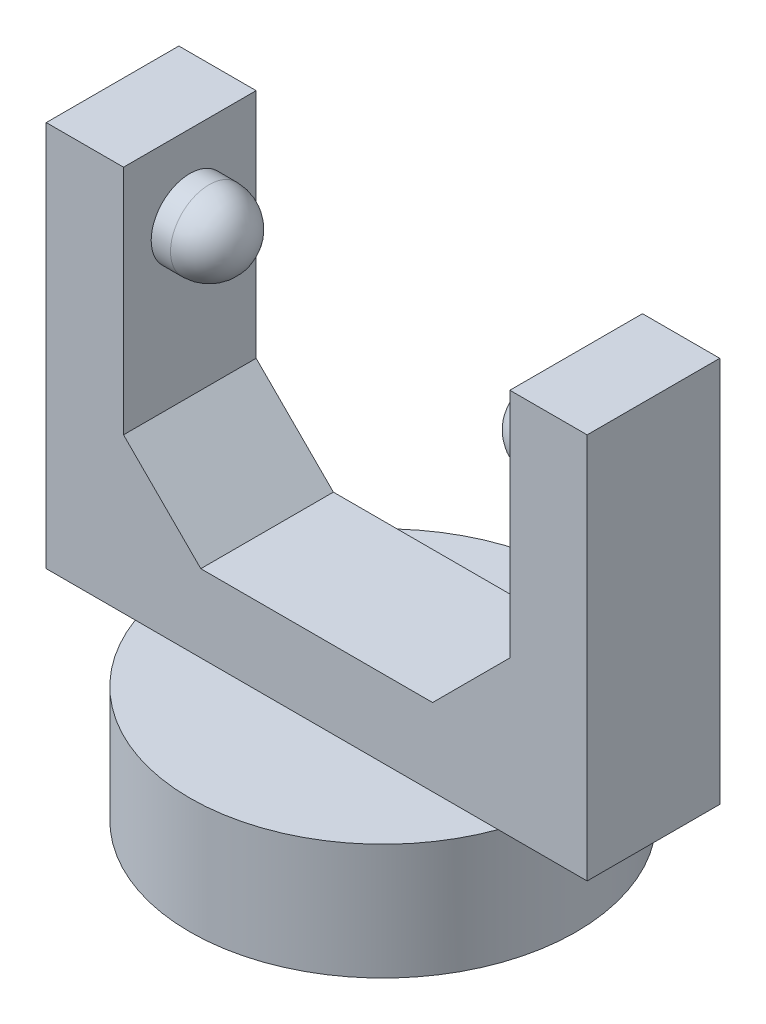
from build123d import *

# Parameters (mm, degrees)
SKETCH1_R           = 12.5
BOSS_EXTRUDE1_DEPTH = 7.5
SKETCH2_W           = 35
SKETCH2_H           = 8.580767914
BOSS_EXTRUDE2_DEPTH = 25
SKETCH3_W           = 25
SKETCH3_H           = 8.580767914
CUT_EXTRUDE1_DEPTH  = 20
SKETCH4_R           = 2.5
BOSS_EXTRUDE3_DEPTH = 3.75
SKETCH5_R           = 2.5
BOSS_EXTRUDE4_DEPTH = 3.75
FILLET2_R           = 2.5
FILLET3_R           = 2.5
CHAMFER1_SIZE       = 5
CHAMFER2_SIZE       = 5


with BuildPart() as part:
    # Sketch1 → Boss-Extrude1 (new body)
    with BuildSketch(Plane(origin=(0, 0, 0), x_dir=(1, 0, 0), z_dir=(0, 1, 0))):
        Circle(SKETCH1_R)
    extrude(amount=BOSS_EXTRUDE1_DEPTH)

    # Sketch2 → Boss-Extrude2 (add)
    with BuildSketch(Plane(origin=(0, 7.5, 0), x_dir=(1, 0, 0), z_dir=(0, 1, 0))):
        Rectangle(SKETCH2_W, SKETCH2_H)
    extrude(amount=BOSS_EXTRUDE2_DEPTH)

    # Sketch3 → Cut-Extrude1 (cut)
    with BuildSketch(Plane(origin=(0, 32.5, 0), x_dir=(1, 0, 0), z_dir=(0, 1, 0))):
        Rectangle(SKETCH3_W, SKETCH3_H)
    extrude(amount=-CUT_EXTRUDE1_DEPTH, mode=Mode.SUBTRACT)

    # Sketch4 → Boss-Extrude3 (add)
    with BuildSketch(Plane(origin=(-12.5, 0, 0), x_dir=(0, 0, -1), z_dir=(1, 0, 0))):
        with Locations((0, 27.5)):
            Circle(SKETCH4_R)
    extrude(amount=BOSS_EXTRUDE3_DEPTH)

    # Sketch5 → Boss-Extrude4 (add)
    with BuildSketch(Plane.ZY.offset(-12.5)):
        with Locations((0, 27.5)):
            Circle(SKETCH5_R)
    extrude(amount=BOSS_EXTRUDE4_DEPTH)

    # Fillet2
    fillet2_edges = [part.edges().sort_by_distance(p)[0] for p in [
        (-8.75, 27.5, 2.5),
    ]]
    fillet(fillet2_edges, radius=FILLET2_R)

    # Fillet3
    fillet3_edges = [part.edges().sort_by_distance(p)[0] for p in [
        (8.75, 27.5, -2.5),
    ]]
    fillet(fillet3_edges, radius=FILLET3_R)

    # Chamfer1
    chamfer1_edges = [part.edges().sort_by_distance(p)[0] for p in [
        (-12.5, 12.5, 0),
    ]]
    chamfer(chamfer1_edges, length=CHAMFER1_SIZE)

    # Chamfer2
    chamfer2_edges = [part.edges().sort_by_distance(p)[0] for p in [
        (12.5, 12.5, 0),
    ]]
    chamfer(chamfer2_edges, length=CHAMFER2_SIZE)


solid = part.part
